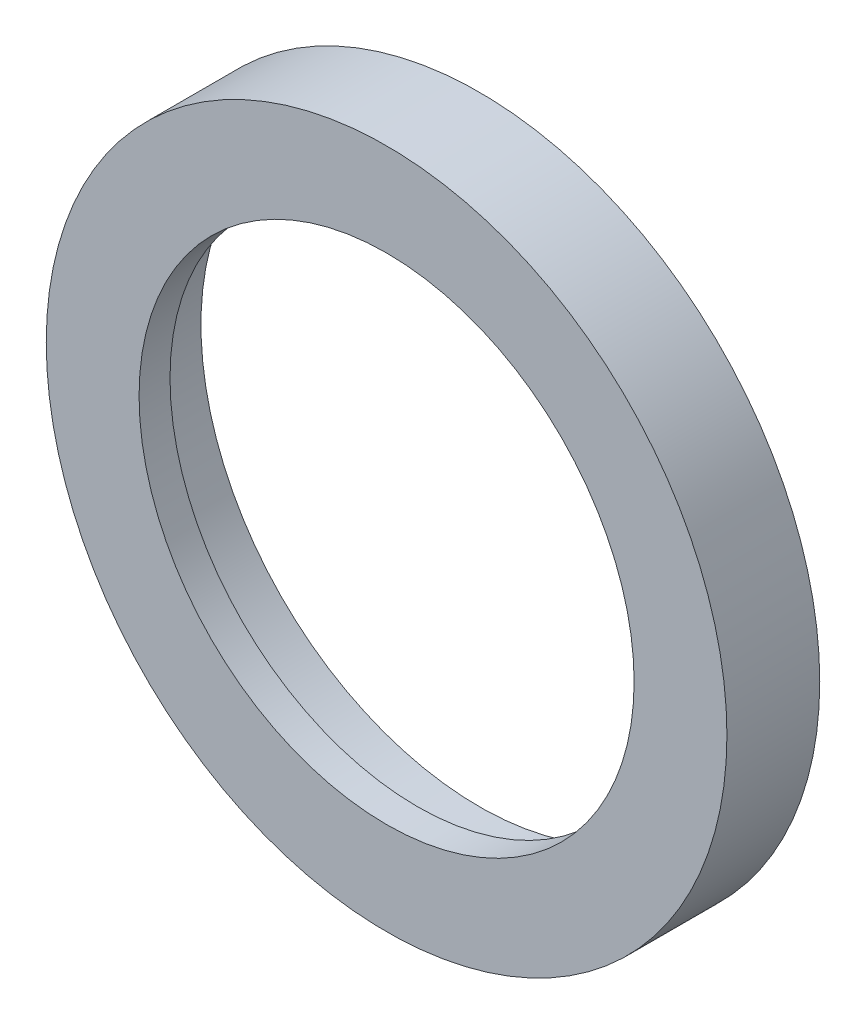
from build123d import *


with BuildPart() as part:
    # Sketch1 → Revolve1 (revolve)
    with BuildSketch(Plane(origin=(0, 0, 0), x_dir=(0, 0, -1), z_dir=(1, 0, 0)), mode=Mode.PRIVATE) as revolve1_sk:
        Polygon((0, 16), (0, 22), (6, 22), (6, 18), (2, 18), (2, 16), align=None)
    revolve(revolve1_sk.sketch.rotate(Axis((0, 0, 0), (0, 0, -1)), 90), axis=Axis((0, 0, 0), (0, 0, -1)))  # turned: the seam where the file's is


solid = part.part
